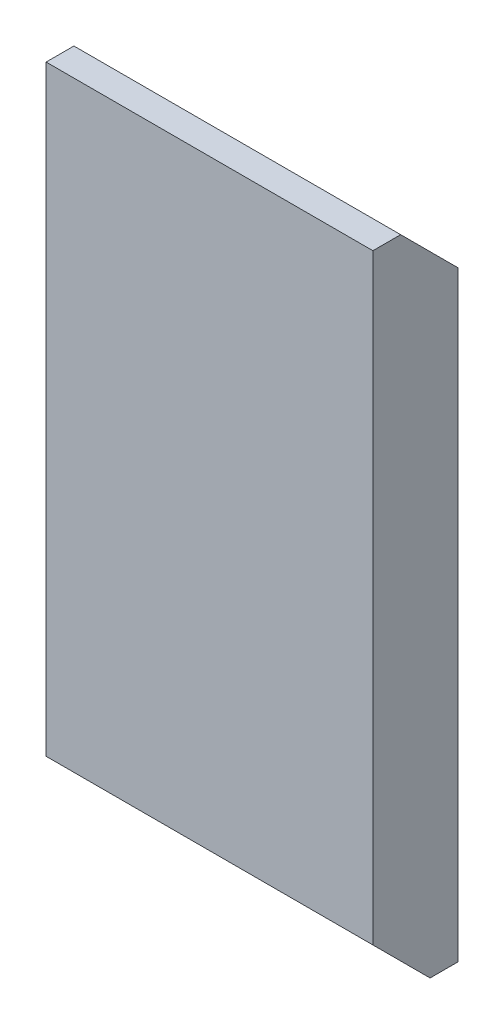
from build123d import *

# Parameters (mm, degrees)
SKETCH1_W           = 25.4
SKETCH1_H           = 51.181
BOSS_EXTRUDE1_DEPTH = 6.604
CHAMFER1_SIZE       = 4.445


with BuildPart() as part:
    # Sketch1 → Boss-Extrude1 (new body)
    with BuildSketch(Plane.XY):
        with Locations((0, -47.625)):
            Rectangle(SKETCH1_W, SKETCH1_H)
    extrude(amount=BOSS_EXTRUDE1_DEPTH)

    # Chamfer1
    chamfer1_edges = [part.edges().sort_by_distance(p)[0] for p in [
        (0, -73.2155, 6.604),
        (0, -22.0345, 0),
    ]]
    chamfer(chamfer1_edges, length=CHAMFER1_SIZE)


solid = part.part
